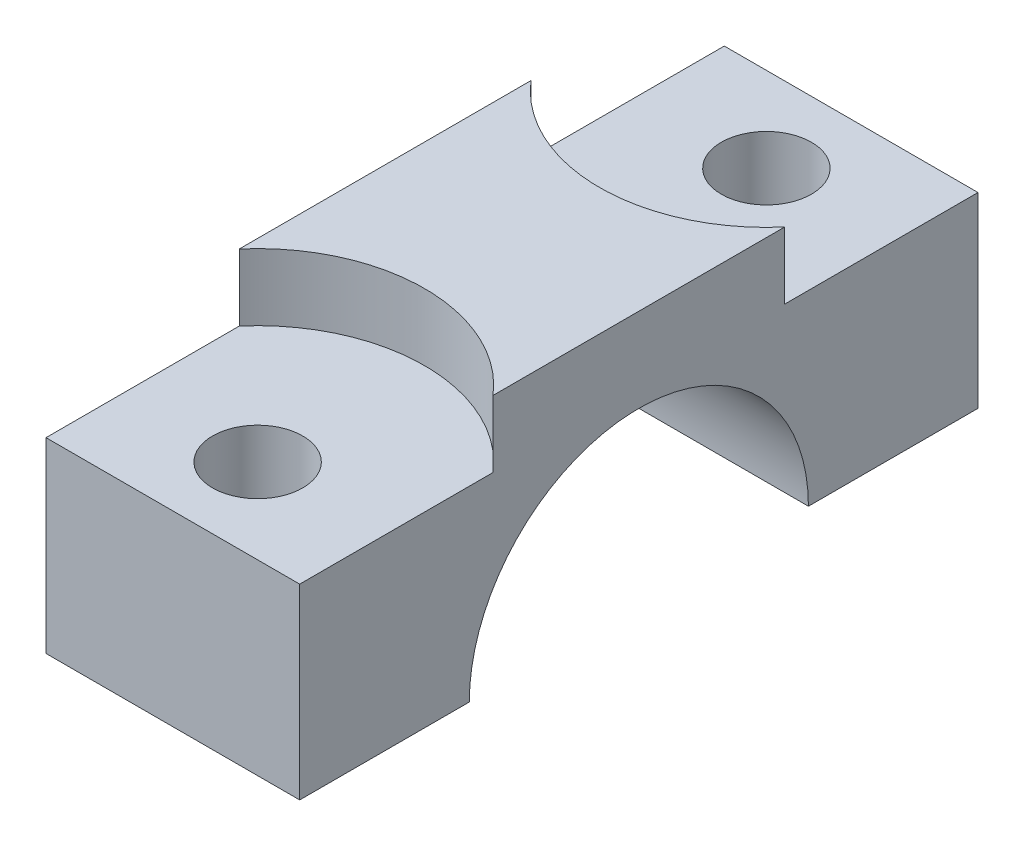
from build123d import *

# Parameters (mm, degrees)
SALIENTE_EXTRUIR1_DEPTH                              = 9.5
REFRENTADO_PARA_TORNILLO_CON_CABEZA_HUEC_D           = 6.75
REFRENTADO_PARA_TORNILLO_CON_CABEZA_HUEC_CBORE_D     = 25
REFRENTADO_PARA_TORNILLO_CON_CABEZA_HUEC_CBORE_DEPTH = 5


with BuildPart() as part:
    # Croquis1 → Saliente-Extruir1 (new body, symmetric)
    with BuildSketch(Plane(origin=(0, 0, 0), x_dir=(0, 0, -1), z_dir=(1, 0, 0))):
        with BuildLine():
            ThreePointArc((-12.7, 0), (0, 12.7), (12.7, 0))
            Line((12.7, 0), (25.4, 0))
            Line((25.4, 0), (25.4, 19))
            Line((25.4, 19), (-25.4, 19))
            Line((-25.4, 19), (-25.4, 0))
            Line((-25.4, 0), (-12.7, 0))
        make_face()
    extrude(amount=SALIENTE_EXTRUIR1_DEPTH, both=True)

    # Refrentado para tornillo con cabeza hueca hexagonal de M121 (through all)
    with Locations(Plane(origin=(0, 19, 0), x_dir=(1, 0, 0), z_dir=(0, 1, 0))):
        with Locations((0, -19.05), (0, 19.05)):
            CounterBoreHole(REFRENTADO_PARA_TORNILLO_CON_CABEZA_HUEC_D / 2, REFRENTADO_PARA_TORNILLO_CON_CABEZA_HUEC_CBORE_D / 2, REFRENTADO_PARA_TORNILLO_CON_CABEZA_HUEC_CBORE_DEPTH)


solid = part.part
